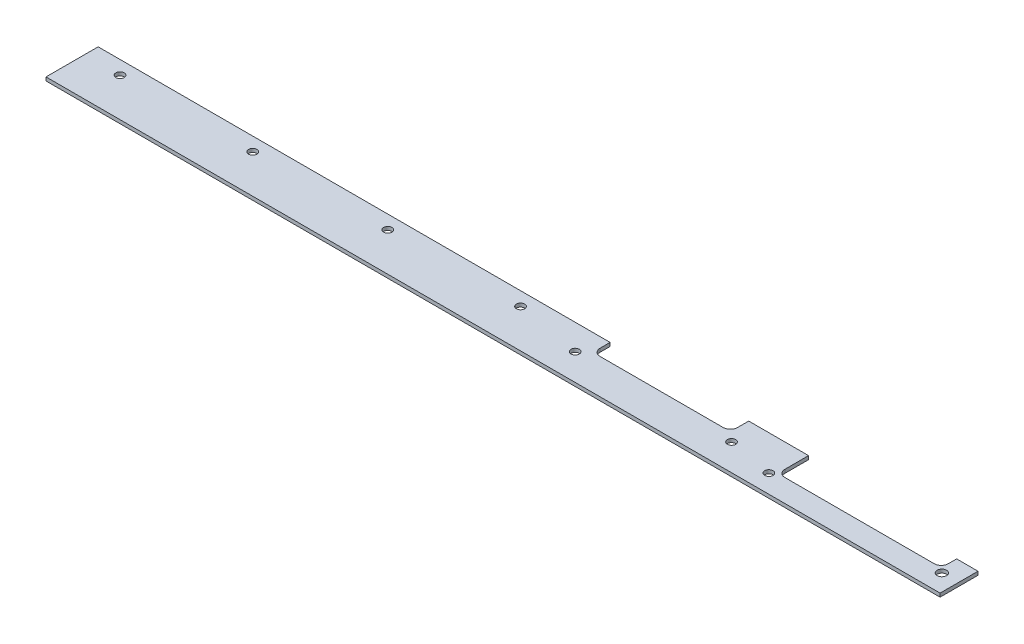
from build123d import *

# Parameters (mm, degrees)
SKETCH_1_R      = 1.75
SKETCH_1_R_2    = 2
EXTRUDE_1_DEPTH = 1.5


with BuildPart() as part:
    # Эскиз1 → Бобышка-Вытянуть1 (new body)
    with BuildSketch(Plane(origin=(0, 0, 0), x_dir=(1, 0, 0), z_dir=(0, 1, 0))):
        with BuildLine():
            Line((299.3, 12.5), (299.3, 22.5))
            Line((299.3, 22.5), (274.05, 22.5))
            Line((274.05, 22.5), (274.05, 17.75))
            ThreePointArc((274.05, 17.75), (273.171320344, 15.628679656), (271.05, 14.75))
            Line((271.05, 14.75), (219.05, 14.75))
            ThreePointArc((219.05, 14.75), (216.928679656, 15.628679656), (216.05, 17.75))
            Line((216.05, 17.75), (216.05, 22))
            Line((216.05, 22), (0, 22))
            Line((0, 22), (0, 0))
            Line((0, 0), (377.3, 0))
            Line((377.3, 0), (377.3, 16))
            Line((377.3, 16), (368.3, 16))
            Line((368.3, 16), (368.3, 12.5))
            ThreePointArc((368.3, 12.5), (367.421320344, 10.378679656), (365.3, 9.5))
            Line((365.3, 9.5), (302.3, 9.5))
            ThreePointArc((302.3, 9.5), (300.178679656, 10.378679656), (299.3, 12.5))
        make_face()
        with Locations((212.05, 11.25)):
            Circle(SKETCH_1_R, mode=Mode.SUBTRACT)
        with Locations((278.05, 11.25)):
            Circle(SKETCH_1_R, mode=Mode.SUBTRACT)
        with Locations((297.3, 7.75)):
            Circle(SKETCH_1_R, mode=Mode.SUBTRACT)
        with Locations((370.3, 7.75)):
            Circle(SKETCH_1_R_2, mode=Mode.SUBTRACT)
        with Locations((15, 16.25)):
            Circle(SKETCH_1_R, mode=Mode.SUBTRACT)
        with Locations((71, 16.25)):
            Circle(SKETCH_1_R, mode=Mode.SUBTRACT)
        with Locations((128, 16.25)):
            Circle(SKETCH_1_R, mode=Mode.SUBTRACT)
        with Locations((184, 16.25)):
            Circle(SKETCH_1_R, mode=Mode.SUBTRACT)
    extrude(amount=EXTRUDE_1_DEPTH)


solid = part.part
